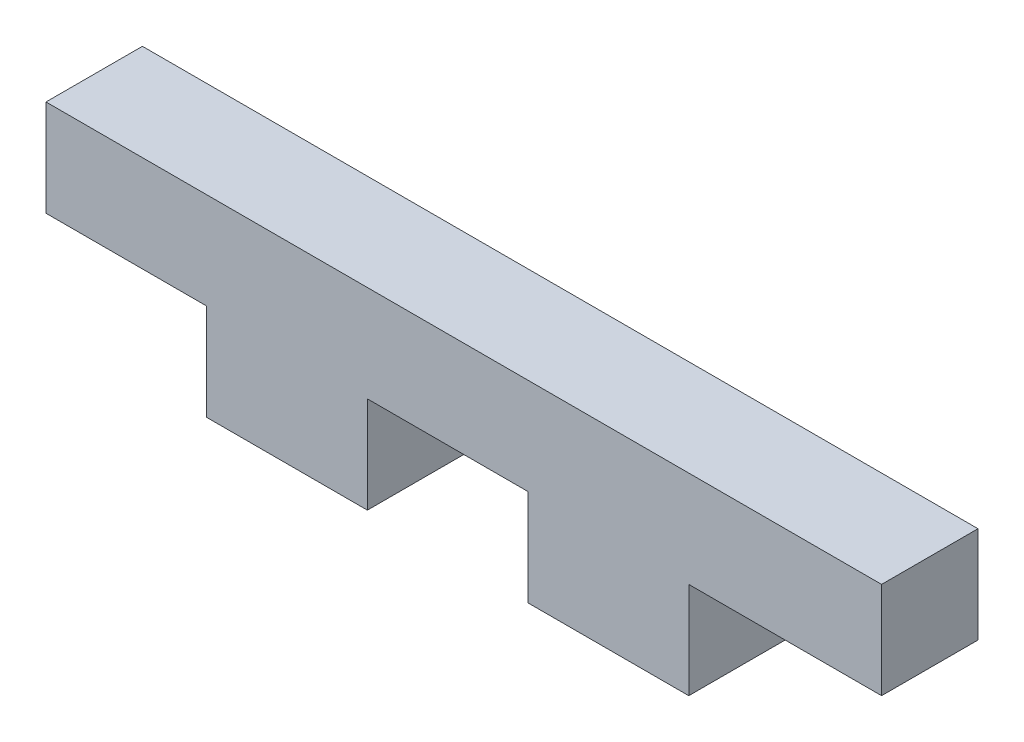
from build123d import *

# Parameters (mm, degrees)
ESQUISSE1_W        = 5
ESQUISSE1_H        = 3
BOSS_EXTRU_1_DEPTH = 3


with BuildPart() as part:
    # Esquisse1 → Boss.-Extru.1 (new body)
    with BuildSketch(Plane.XY):
        with Locations((6.490106642, -1.399569673)):
            Rectangle(ESQUISSE1_W, ESQUISSE1_H)
        with Locations((16.490106642, -1.399569673)):
            Rectangle(ESQUISSE1_W, ESQUISSE1_H)
        Polygon((-1.009893358, 0.100430327), (3.990106642, 0.100430327), (8.990106642, 0.100430327), (13.990106642, 0.100430327), (18.990106642, 0.100430327), (24.990106642, 0.100430327), (24.990106642, 3.100430327), (-1.009893358, 3.100430327), align=None)
    extrude(amount=BOSS_EXTRU_1_DEPTH)


solid = part.part
